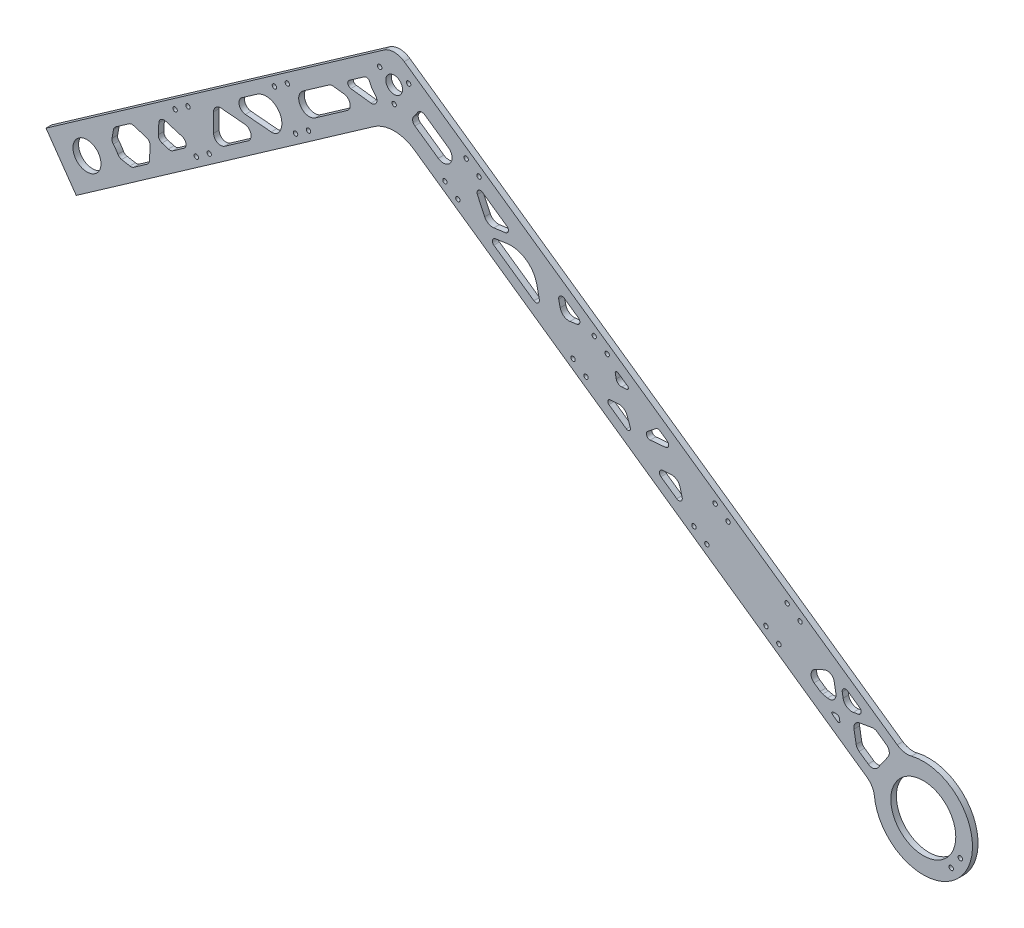
from build123d import *

# Parameters (mm, degrees)
SKETCH2_R                        = 7.9756
SKETCH2_R_2                      = 4.7625
BASE_DEPTH                       = 3.175
FILLET1_R                        = 20
FILLET2_R                        = 10
LIGHTENING_HOLES_DEPTH           = 4.175
SKETCH6_R                        = 1.25
SHAFT_CONNECTION_DEPTH           = 4.175
SKETCH8_R                        = 1.25
FRAME_SUPPORTS_DEPTH             = 4.175
EXTRA_MATERIAL_DEPTH             = 3.175
SKETCH10_R                       = 18.5
HOLE_FOR_MOTOR_DEPTH             = 4.175
SKETCH11_R                       = 1.25
EXTRA_SUPPORT_HOUSING_SIDE_DEPTH = 4.175
FILLET3_R                        = 10


with BuildPart() as part:
    # Sketch2 → Base (new body)
    with BuildSketch(Plane.XY):
        Polygon((0, 0), (-17.207293091, 24.574561329), (-9.015772648, 30.310325692), (180.953522494, 163.328258179), (504.65033424, -63.3266895), (487.44304115, -87.901250829), (180.953522494, 126.705020516), align=None)
        with Locations((6.121102942, 22.597661254)):
            Circle(SKETCH2_R, mode=Mode.SUBTRACT)
        with Locations((180.953522494, 145.016639348)):
            Circle(SKETCH2_R_2, mode=Mode.SUBTRACT)
    extrude(amount=BASE_DEPTH)

    # Fillet1
    fillet1_edges = [part.edges().sort_by_distance(p)[0] for p in [
        (180.953522494, 126.705020516, 1.5875),
    ]]
    fillet(fillet1_edges, radius=FILLET1_R)

    # Fillet2
    fillet2_edges = [part.edges().sort_by_distance(p)[0] for p in [
        (180.953522494, 163.328258179, 1.5875),
    ]]
    fillet(fillet2_edges, radius=FILLET2_R)

    # Sketch5 → Lightening Holes (cut, through all)
    with BuildSketch(Plane.XY.offset(3.175)):
        with BuildLine():
            Line((21.221933831, 43.085678378), (20.389165903, 38.362816767))
            ThreePointArc((20.389165903, 38.362816767), (20.456316842, 37.027219823), (21.097177916, 35.853496888))
            ThreePointArc((21.097177916, 35.853496888), (22.504143828, 34.069189981), (23.699633179, 32.136805591))
            ThreePointArc((23.699633179, 32.136805591), (24.583384564, 31.133156283), (25.815468182, 30.613253983))
            Line((25.815468182, 30.613253983), (30.538329794, 29.780486055))
            ThreePointArc((30.538329794, 29.780486055), (31.708593168, 29.806021292), (32.780003636, 30.277453181))
            Line((32.780003636, 30.277453181), (40.393335067, 35.60836524))
            ThreePointArc((40.393335067, 35.60836524), (41.296464879, 36.611392512), (41.668494362, 37.908813504))
            Line((41.668494362, 37.908813504), (42.066986053, 45.512487922))
            ThreePointArc((42.066986053, 45.512487922), (41.528553581, 47.3902251), (39.948212563, 48.538410059))
            Line((39.948212563, 48.538410059), (32.666803636, 50.764560172))
            ThreePointArc((32.666803636, 50.764560172), (31.320385127, 50.858710926), (30.068959213, 50.353102037))
            Line((30.068959213, 50.353102037), (22.455627781, 45.022189978))
            ThreePointArc((22.455627781, 45.022189978), (21.646182753, 44.17663267), (21.221933831, 43.085678378))
        make_face()
        with BuildLine():
            Line((46.698324267, 53.264889158), (47.017103083, 59.347551311))
            ThreePointArc((47.017103083, 59.347551311), (48.292262378, 61.647999576), (50.890106801, 62.059457711))
            Line((50.890106801, 62.059457711), (60.355672781, 59.165543773))
            ThreePointArc((60.355672781, 59.165543773), (62.441622689, 56.7659329), (61.199286976, 53.839173372))
            Line((61.199286976, 53.839173372), (55.055646644, 49.5373501))
            ThreePointArc((55.055646644, 49.5373501), (53.80422073, 49.031741211), (52.45780222, 49.125891965))
            Line((52.45780222, 49.125891965), (48.817097757, 50.238967021))
            ThreePointArc((48.817097757, 50.238967021), (47.236756738, 51.38715198), (46.698324267, 53.264889158))
        make_face()
        with BuildLine():
            Line((143.729636686, 126.276841436), (129.176143076, 116.086375503))
            ThreePointArc((129.176143076, 116.086375503), (127.702689428, 107.730004619), (136.059060312, 106.256550971))
            Line((136.059060312, 106.256550971), (154.25159597, 118.995101578))
            ThreePointArc((154.25159597, 118.995101578), (155.838473129, 123.239397337), (152.444767598, 126.241894361))
            Line((152.444767598, 126.241894361), (146.511419805, 126.970417865))
            ThreePointArc((146.511419805, 126.970417865), (145.056254849, 126.881416163), (143.729636686, 126.276841436))
        make_face()
        with BuildLine():
            Line((82.511657948, 84.258042008), (95.885266773, 83.088002846))
            ThreePointArc((95.885266773, 83.088002846), (99.400347108, 80.138500234), (97.830949548, 75.826615876))
            Line((97.830949548, 75.826615876), (84.457340722, 66.462314163))
            ThreePointArc((84.457340722, 66.462314163), (80.316040524, 66.190879008), (78.163034977, 69.738922341))
            Line((78.163034977, 69.738922341), (78.163034977, 80.273263216))
            ThreePointArc((78.163034977, 80.273263216), (79.460674146, 83.222372563), (82.511657948, 84.258042008))
        make_face()
        with BuildLine():
            Line((163.977450858, 140.454513551), (155.376354393, 134.431960969))
            ThreePointArc((155.376354393, 134.431960969), (154.582915813, 132.309813089), (156.279768578, 130.808564577))
            Line((156.279768578, 130.808564577), (167.764073452, 129.398469246))
            ThreePointArc((167.764073452, 129.398469246), (170.824941709, 131.053135413), (170.269520523, 134.488006869))
            ThreePointArc((170.269520523, 134.488006869), (168.371424711, 136.850194872), (166.986829467, 139.545671802))
            ThreePointArc((166.986829467, 139.545671802), (165.70281704, 140.730803249), (163.977450858, 140.454513551))
        make_face()
        with BuildLine():
            Line((110.951708103, 86.788959217), (96.256849142, 88.074592789))
            ThreePointArc((96.256849142, 88.074592789), (92.741768808, 91.024095401), (94.311166367, 95.335979758))
            Line((94.311166367, 95.335979758), (102.880852438, 101.336538545))
            ThreePointArc((102.880852438, 101.336538545), (114.310102984, 100.423576167), (115.56804488, 89.02713591))
            ThreePointArc((115.56804488, 89.02713591), (113.568817103, 87.270844114), (110.951708103, 86.788959217))
        make_face()
        with BuildLine():
            Line((206.053240505, 121.337754646), (192.739077552, 130.66043191))
            ThreePointArc((192.739077552, 130.66043191), (191.480974333, 132.762139857), (192.208759467, 135.101013261))
            ThreePointArc((192.208759467, 135.101013261), (193.240803159, 136.412992802), (194.120680921, 137.831520075))
            ThreePointArc((194.120680921, 137.831520075), (196.069585824, 139.315356211), (198.474841916, 138.851952353))
            Line((198.474841916, 138.851952353), (211.789004869, 129.529275088))
            ThreePointArc((211.789004869, 129.529275088), (213.016882908, 122.565632685), (206.053240505, 121.337754646))
        make_face()
        with BuildLine():
            Line((228.302122348, 114.631447549), (232.466025934, 105.701927492))
            ThreePointArc((232.466025934, 105.701927492), (234.611771068, 103.420933238), (237.693430374, 102.863678457))
            Line((237.693430374, 102.863678457), (244.259856406, 103.786529453))
            ThreePointArc((244.259856406, 103.786529453), (245.926250045, 105.300174862), (245.128663077, 107.405369679))
            Line((245.128663077, 107.405369679), (231.261890794, 117.114988161))
            ThreePointArc((231.261890794, 117.114988161), (228.829162702, 117.008772959), (228.302122348, 114.631447549))
        make_face()
        with BuildLine():
            Line((238.541010302, 97.933660185), (245.387921464, 98.895930795))
            ThreePointArc((245.387921464, 98.895930795), (256.079164523, 96.329190428), (262.147731989, 87.160585126))
            Line((262.147731989, 87.160585126), (263.585274935, 80.397477301))
            ThreePointArc((263.585274935, 80.397477301), (262.732853704, 78.313882275), (260.481826861, 78.34334983))
            Line((260.481826861, 78.34334983), (237.672203631, 94.314819959))
            ThreePointArc((237.672203631, 94.314819959), (236.874616663, 96.420014775), (238.541010302, 97.933660185))
        make_face()
        with BuildLine():
            Line((274.622381825, 86.188784042), (275.440182374, 82.341334954))
            ThreePointArc((275.440182374, 82.341334954), (277.463038196, 79.285133187), (281.026785882, 78.429553064))
            Line((281.026785882, 78.429553064), (284.92190966, 78.976977011))
            ThreePointArc((284.92190966, 78.976977011), (286.588303299, 80.490622421), (285.790716331, 82.595817237))
            Line((285.790716331, 82.595817237), (277.725829899, 88.242911512))
            ThreePointArc((277.725829899, 88.242911512), (275.474803056, 88.272379067), (274.622381825, 86.188784042))
        make_face()
        with BuildLine():
            Line((313.848740225, 62.9493774), (308.349056051, 66.800297715))
            ThreePointArc((308.349056051, 66.800297715), (307.22354263, 66.815031493), (306.797332014, 65.77323398))
            Line((306.797332014, 65.77323398), (307.333443599, 63.251027278))
            ThreePointArc((307.333443599, 63.251027278), (308.483418041, 61.463191769), (310.529353629, 60.886178257))
            Line((310.529353629, 60.886178257), (313.362319531, 61.134030657))
            ThreePointArc((313.362319531, 61.134030657), (314.241089615, 61.87140631), (313.848740225, 62.9493774))
        make_face()
        with BuildLine():
            Line((313.106290368, 41.495303789), (303.177027604, 48.447848425))
            ThreePointArc((303.177027604, 48.447848425), (302.588503519, 50.064805059), (303.906658644, 51.170868538))
            Line((303.906658644, 51.170868538), (308.401647912, 51.564129142))
            ThreePointArc((308.401647912, 51.564129142), (311.523924668, 50.800112881), (313.53588973, 48.293256368))
            Line((313.53588973, 48.293256368), (315.376193953, 43.23706207))
            ThreePointArc((315.376193953, 43.23706207), (314.879797166, 41.534001845), (313.106290368, 41.495303789))
        make_face()
        with BuildLine():
            Line((325.28241676, 46.34148234), (329.882929868, 49.980403215))
            ThreePointArc((329.882929868, 49.980403215), (331.065330871, 50.410937491), (332.270827857, 50.05009277))
            Line((332.270827857, 50.05009277), (336.379554197, 47.173131614))
            ThreePointArc((336.379554197, 47.173131614), (337.164252977, 45.017189436), (335.406712809, 43.54243813))
            Line((335.406712809, 43.54243813), (326.697473362, 42.78047841))
            ThreePointArc((326.697473362, 42.78047841), (324.664531354, 44.034293111), (325.28241676, 46.34148234))
        make_face()
        with BuildLine():
            Line((344.87592703, 23.561849069), (343.667493871, 28.071783014))
            ThreePointArc((343.667493871, 28.071783014), (341.705746922, 30.87344801), (338.402086026, 31.758661279))
            Line((338.402086026, 31.758661279), (333.750825896, 31.351728746))
            ThreePointArc((333.750825896, 31.351728746), (331.993285729, 29.87697744), (332.777984509, 27.721035261))
            Line((332.777984509, 27.721035261), (341.796922504, 21.40590689))
            ThreePointArc((341.796922504, 21.40590689), (344.09122825, 21.40590689), (344.87592703, 23.561849069))
        make_face()
        with BuildLine():
            Line((462.052727884, -45.707270307), (456.31696352, -53.89879075))
            ThreePointArc((456.31696352, -53.89879075), (453.734948054, -55.543716017), (450.746049598, -54.881093182))
            Line((450.746049598, -54.881093182), (445.550048789, -51.242814247))
            ThreePointArc((445.550048789, -51.242814247), (444.470788751, -50.115404503), (443.905123522, -48.66079878))
            Line((443.905123522, -48.66079878), (442.677245483, -41.697156377))
            ThreePointArc((442.677245483, -41.697156377), (443.339868317, -38.708257921), (445.921883784, -37.063332655))
            Line((445.921883784, -37.063332655), (452.885526187, -35.835454615))
            ThreePointArc((452.885526187, -35.835454615), (454.445877354, -35.869501598), (455.874424643, -36.49807745))
            Line((455.874424643, -36.49807745), (461.070425452, -40.136356385))
            ThreePointArc((461.070425452, -40.136356385), (462.715350719, -42.718371851), (462.052727884, -45.707270307))
        make_face()
        with BuildLine():
            Line((445.128312908, -33.141554164), (442.272867814, -33.645046175))
            ThreePointArc((442.272867814, -33.645046175), (438.536744744, -32.816767632), (436.480588161, -29.589248299))
            Line((436.480588161, -29.589248299), (435.977096149, -26.733803205))
            ThreePointArc((435.977096149, -26.733803205), (436.872112438, -24.699723958), (439.093864528, -24.748202761))
            Line((439.093864528, -24.748202761), (445.928169425, -29.533634569))
            ThreePointArc((445.928169425, -29.533634569), (446.733608567, -31.604817885), (445.128312908, -33.141554164))
        make_face()
        with BuildLine():
            Line((430.750665545, -39.214593597), (432.857440341, -39.214593597))
            ThreePointArc((432.857440341, -39.214593597), (433.821621756, -39.565526933), (434.334651971, -40.454121331))
            Line((434.334651971, -40.454121331), (434.610767959, -42.020052913))
            ThreePointArc((434.610767959, -42.020052913), (434.27513685, -42.782832631), (433.441979817, -42.764653079))
            Line((433.441979817, -42.764653079), (430.320483218, -40.578957631))
            ThreePointArc((430.320483218, -40.578957631), (430.035377832, -39.739064248), (430.750665545, -39.214593597))
        make_face()
        with BuildLine():
            Line((431.410035699, -23.867798241), (432.373975859, -29.334574541))
            ThreePointArc((432.373975859, -29.334574541), (431.205825445, -32.913801079), (427.582594956, -33.937343369))
            Line((427.582594956, -33.937343369), (424.898144224, -33.352018059))
            ThreePointArc((424.898144224, -33.352018059), (424.145686598, -33.107888164), (423.455988369, -32.720450119))
            Line((423.455988369, -32.720450119), (419.959108305, -30.271908338))
            ThreePointArc((419.959108305, -30.271908338), (418.268635258, -26.64667719), (420.562941004, -23.370069013))
            Line((420.562941004, -23.370069013), (425.78033164, -20.937159804))
            ThreePointArc((425.78033164, -20.937159804), (429.31779914, -21.014347619), (431.410035699, -23.867798241))
        make_face()
    extrude(amount=-LIGHTENING_HOLES_DEPTH, mode=Mode.SUBTRACT)

    # Sketch6 → Shaft Connection (cut, through all)
    with BuildSketch(Plane.XY.offset(3.175)):
        with Locations((180.953522494, 135.504139348)):
            Circle(SKETCH6_R)
        with Locations((172.715455841, 149.772889348)):
            Circle(SKETCH6_R)
        with Locations((189.191589148, 149.772889348)):
            Circle(SKETCH6_R)
    extrude(amount=-SHAFT_CONNECTION_DEPTH, mode=Mode.SUBTRACT)

    # Sketch8 → Frame Supports (cut, through all)
    with BuildSketch(Plane.XY.offset(3.175)):
        with Locations((411.962515405, -3.919465701)):
            Circle(SKETCH8_R)
        with Locations((363.632544792, 29.921544044)):
            Circle(SKETCH8_R)
        with Locations((112.790897887, 110.106788955)):
            Circle(SKETCH8_R)
        with Locations((404.590147006, 1.242722226)):
            Circle(SKETCH8_R)
        with Locations((371.00491319, 24.759356117)):
            Circle(SKETCH8_R)
        with Locations((120.163266286, 115.268976882)):
            Circle(SKETCH8_R)
        with Locations((392.545041843, -15.959470704)):
            Circle(SKETCH8_R)
        with Locations((399.917410241, -21.121658631)):
            Circle(SKETCH8_R)
        with Locations((302.19614147, 72.93977677)):
            Circle(SKETCH8_R)
        with Locations((294.823773072, 78.101964697)):
            Circle(SKETCH8_R)
        with Locations((63.64177523, 75.692202774)):
            Circle(SKETCH8_R)
        with Locations((56.269406831, 70.530014847)):
            Circle(SKETCH8_R)
        with Locations((68.314511994, 53.327821917)):
            Circle(SKETCH8_R)
        with Locations((75.686880393, 58.490009844)):
            Circle(SKETCH8_R)
        with Locations((282.778667908, 60.899771767)):
            Circle(SKETCH8_R)
        with Locations((290.151036307, 55.73758384)):
            Circle(SKETCH8_R)
        with Locations((351.587439628, 12.719351114)):
            Circle(SKETCH8_R)
        with Locations((358.959808027, 7.557163187)):
            Circle(SKETCH8_R)
        with Locations((124.83600305, 92.904596025)):
            Circle(SKETCH8_R)
        with Locations((132.208371449, 98.066783952)):
            Circle(SKETCH8_R)
        with Locations((221.91924113, 129.150267533)):
            Circle(SKETCH8_R)
        with Locations((229.291609528, 123.988079606)):
            Circle(SKETCH8_R)
        with Locations((209.874135966, 111.948074603)):
            Circle(SKETCH8_R)
        with Locations((217.246504365, 106.785886676)):
            Circle(SKETCH8_R)
    extrude(amount=-FRAME_SUPPORTS_DEPTH, mode=Mode.SUBTRACT)

    # Sketch9 → Extra Material (add)
    with BuildSketch(Plane.XY.offset(3.175)):
        with BuildLine():
            Line((471.357389573, -40.014718675), (454.150096482, -64.589280003))
            ThreePointArc((454.150096482, -64.589280003), (505.057360182, -81.923310964), (471.357389573, -40.014718675))
        make_face()
    extrude(amount=-EXTRA_MATERIAL_DEPTH)

    # Sketch10 → Hole for Motor (cut, through all)
    with BuildSketch(Plane.XY.offset(3.175)):
        with Locations((482.121102942, -65.863170746)):
            Circle(SKETCH10_R)
    extrude(amount=-HOLE_FOR_MOTOR_DEPTH, mode=Mode.SUBTRACT)

    # Sketch11 → Extra Support Housing Side (cut, through all)
    with BuildSketch(Plane.XY.offset(3.175)):
        with Locations((503.178570304, -75.114282479)):
            Circle(SKETCH11_R)
        with Locations((498.016382377, -82.486650878)):
            Circle(SKETCH11_R)
    extrude(amount=-EXTRA_SUPPORT_HOUSING_SIDE_DEPTH, mode=Mode.SUBTRACT)

    # Fillet3
    fillet3_edges = [part.edges().sort_by_distance(p)[0] for p in [
        (454.150096482, -64.589280003, 1.5875),
        (471.357389573, -40.014718675, 1.5875),
    ]]
    fillet(fillet3_edges, radius=FILLET3_R)


solid = part.part
